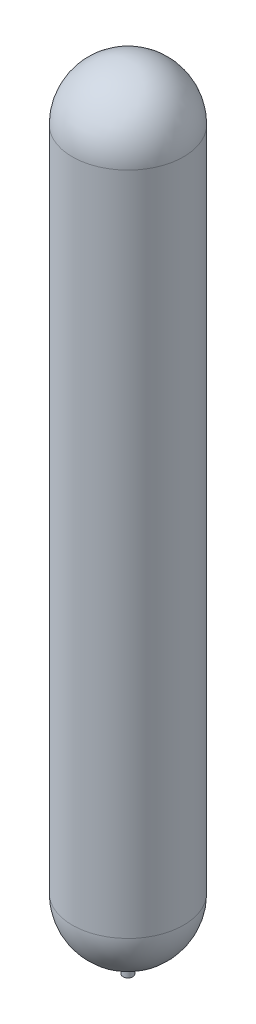
from build123d import *


with BuildPart() as part:
    # Sketch1 (on Front Plane) → Revolve1 (revolve)
    with BuildSketch(Plane.XY):
        with BuildLine():
            Line((-114.7826, 1729.74), (-114.7826, 0))
            ThreePointArc((-114.7826, 0), (-82.278429791, -80.033150968), (-3.175, -114.73867978))
            Line((-3.175, -114.73867978), (-3.175, -182.321906796))
            Line((-3.175, -182.321906796), (-12.7, -182.321906796))
            Line((-12.7, -182.321906796), (-12.7, -140.881326111))
            ThreePointArc((-12.7, -140.881326111), (-104.415722156, -95.42638531), (-141.4526, 0))
            Line((-141.4526, 0), (-141.4526, 1729.74))
            ThreePointArc((-141.4526, 1729.74), (-100.022092676, 1829.762092676), (0, 1871.1926))
            Line((0, 1871.1926), (0, 1844.5226))
            ThreePointArc((0, 1844.5226), (-81.163554822, 1810.903554822), (-114.7826, 1729.74))
        make_face()
    revolve(axis=Axis((0, 50.358015581, 0), (0, -1, 0)))


with BuildPart() as body_2:
    # Sketch1_4 → Revolve2 (revolve)
    with BuildSketch(Plane.XY):
        with BuildLine():
            ThreePointArc((-141.4526, 1729.74), (-100.022092676, 1829.762092676), (0, 1871.1926))
            Line((0, 1871.1926), (0, 1874.52))
            ThreePointArc((0, 1874.52), (-102.37491978, 1832.11491978), (-144.78, 1729.74))
            Line((-144.78, 1729.74), (-144.78, 0))
            ThreePointArc((-144.78, 0), (-106.770675749, -97.781752899), (-12.7, -144.221906796))
            Line((-12.7, -144.221906796), (-12.7, -140.881326111))
            ThreePointArc((-12.7, -140.881326111), (-104.415722156, -95.42638531), (-141.4526, 0))
            Line((-141.4526, 0), (-141.4526, 1729.74))
        make_face()
    revolve(axis=Axis((0, 50.358015581, 0), (0, -1, 0)))


solid = Compound([part.part, body_2.part])
